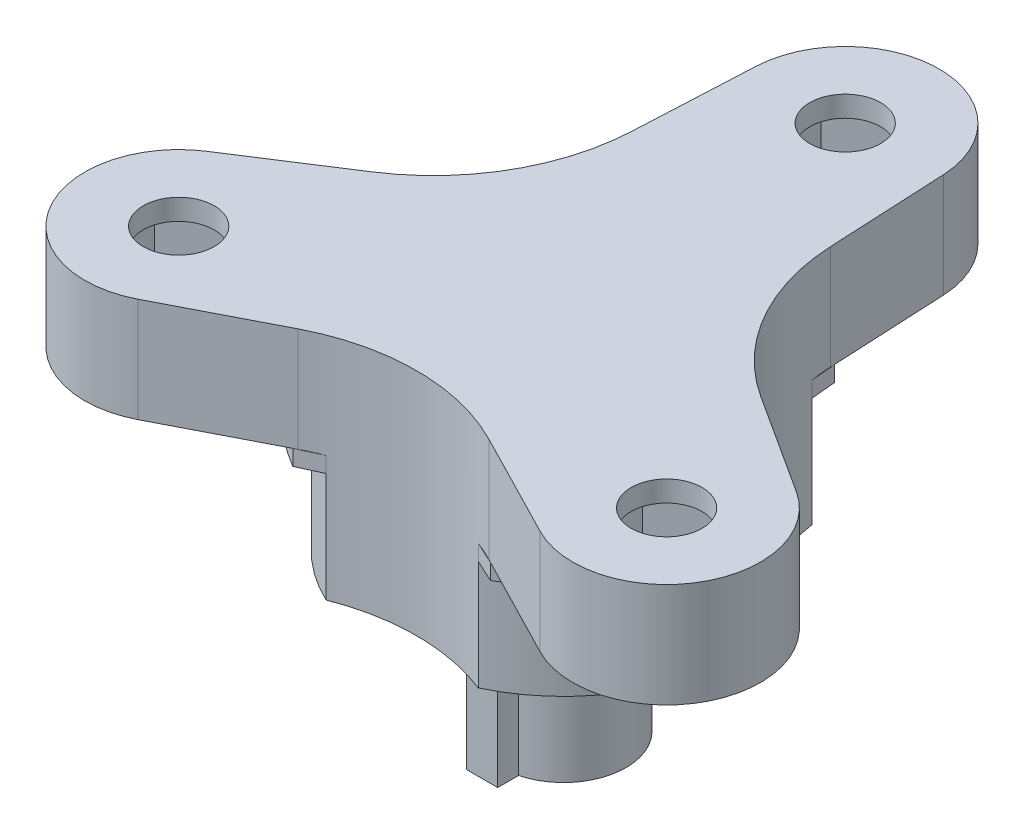
from build123d import *

# Parameters (mm, degrees)
SKETCH1_R           = 1.7
BOSS_EXTRUDE1_DEPTH = 5
CUT_EXTRUDE1_START  = -5
CUT_EXTRUDE1_DEPTH  = 4
BOSS_EXTRUDE2_DEPTH = 6
BOSS_EXTRUDE3_DEPTH = 0.75
BOSS_EXTRUDE4_DEPTH = 7.5
SKETCH7_R           = 1.3
CUT_EXTRUDE2_DEPTH  = 7.5


with BuildPart() as part:
    # Sketch1 → Boss-Extrude1 (new body)
    with BuildSketch(Plane(origin=(0, 0, 0), x_dir=(1, 0, 0), z_dir=(0, 1, 0))):
        with BuildLine():
            Line((-4.494644994, 13.719468408), (-4.772250922, 8.034184997))
            ThreePointArc((-4.772250922, 8.034184997), (-6.10009687, 3.52189257), (-9.343933767, 0.115798034))
            Line((-9.343933767, 0.115798034), (-14.128730664, -2.967257459))
            ThreePointArc((-14.128730664, -2.967257459), (-15.588457268, -9), (-9.634085671, -10.752210949))
            Line((-9.634085671, -10.752210949), (-4.571682845, -8.149983031))
            ThreePointArc((-4.571682845, -8.149983031), (0, -7.04378514), (4.571682845, -8.149983031))
            Line((4.571682845, -8.149983031), (9.634085671, -10.752210949))
            ThreePointArc((9.634085671, -10.752210949), (15.588457268, -9), (14.128730664, -2.967257459))
            Line((14.128730664, -2.967257459), (9.343933767, 0.115798034))
            ThreePointArc((9.343933767, 0.115798034), (6.10009687, 3.52189257), (4.772250922, 8.034184997))
            Line((4.772250922, 8.034184997), (4.494644994, 13.719468408))
            ThreePointArc((4.494644994, 13.719468408), (0, 18), (-4.494644994, 13.719468408))
        make_face()
        with Locations((0, 13.5)):
            Circle(SKETCH1_R, mode=Mode.SUBTRACT)
        with Locations((11.691342951, -6.75)):
            Circle(SKETCH1_R, mode=Mode.SUBTRACT)
        with Locations((-11.691342951, -6.75)):
            Circle(SKETCH1_R, mode=Mode.SUBTRACT)
    extrude(amount=BOSS_EXTRUDE1_DEPTH)

    # Sketch2 → Cut-Extrude1 (cut)
    with BuildSketch(Plane(origin=(0, 5, 0), x_dir=(1, 0, 0), z_dir=(0, 1, 0)).offset(CUT_EXTRUDE1_START)):
        Polygon((14.441342951, -8.33771324), (14.441342951, -5.16228676), (11.691342951, -3.574573519), (8.941342951, -5.16228676), (8.941342951, -8.33771324), (11.691342951, -9.925426481), align=None)
        Polygon((0, 16.675426481), (-2.75, 15.08771324), (-2.75, 11.91228676), (0, 10.324573519), (2.75, 11.91228676), (2.75, 15.08771324), align=None)
        Polygon((-14.441342951, -8.33771324), (-11.691342951, -9.925426481), (-8.941342951, -8.33771324), (-8.941342951, -5.16228676), (-11.691342951, -3.574573519), (-14.441342951, -5.16228676), align=None)
    extrude(amount=CUT_EXTRUDE1_DEPTH, mode=Mode.SUBTRACT)

    # Sketch4 → Boss-Extrude2 (add)
    with BuildSketch(Plane.XZ):
        with BuildLine():
            ThreePointArc((-4.872953171, -7.025441438), (0, -8.55), (4.872953171, -7.025441438))
            ThreePointArc((4.872953171, -7.025441438), (6.10009687, -3.52189257), (8.520687343, -0.707380519))
            ThreePointArc((8.520687343, -0.707380519), (7.404517202, 4.275), (3.647734172, 7.732821956))
            ThreePointArc((3.647734172, 7.732821956), (0, 7.04378514), (-3.647734172, 7.732821956))
            ThreePointArc((-3.647734172, 7.732821956), (-7.404517202, 4.275), (-8.520687343, -0.707380519))
            ThreePointArc((-8.520687343, -0.707380519), (-6.10009687, -3.52189257), (-4.872953171, -7.025441438))
        make_face()
    extrude(amount=BOSS_EXTRUDE2_DEPTH)

    # Sketch5 → Boss-Extrude3 (add)
    with BuildSketch(Plane.XZ):
        with BuildLine():
            Line((-9.499987767, -0.015245565), (-8.520687343, -0.707380519))
            ThreePointArc((-8.520687343, -0.707380519), (-7.404517202, 4.275), (-3.647734172, 7.732821956))
            Line((-3.647734172, 7.732821956), (-4.736790837, 8.234853524))
            ThreePointArc((-4.736790837, 8.234853524), (-8.227241336, 4.75), (-9.499987767, -0.015245565))
        make_face()
        with BuildLine():
            Line((9.499987767, -0.015245565), (8.520687343, -0.707380519))
            ThreePointArc((8.520687343, -0.707380519), (7.404517202, 4.275), (3.647734172, 7.732821956))
            Line((3.647734172, 7.732821956), (4.736790837, 8.234853524))
            ThreePointArc((4.736790837, 8.234853524), (8.227241336, 4.75), (9.499987767, -0.015245565))
        make_face()
        with BuildLine():
            Line((-4.76319693, -8.219607959), (-4.872953171, -7.025441438))
            ThreePointArc((-4.872953171, -7.025441438), (0, -8.55), (4.872953171, -7.025441438))
            Line((4.872953171, -7.025441438), (4.76319693, -8.219607959))
            ThreePointArc((4.76319693, -8.219607959), (0, -9.5), (-4.76319693, -8.219607959))
        make_face()
    extrude(amount=BOSS_EXTRUDE3_DEPTH)

    # Sketch6 → Boss-Extrude4 (add)
    with BuildSketch(Plane.XZ.offset(6)):
        with BuildLine():
            Line((-0.75, 2.90473751), (-0.75, 3.90473751))
            Line((-0.75, 3.90473751), (0.75, 3.90473751))
            Line((0.75, 3.90473751), (0.75, 2.90473751))
            ThreePointArc((0.75, 2.90473751), (0, -3), (-0.75, 2.90473751))
        make_face()
    extrude(amount=BOSS_EXTRUDE4_DEPTH)

    # Sketch7 → Cut-Extrude2 (cut)
    with BuildSketch(Plane.XZ.offset(13.5)):
        Circle(SKETCH7_R)
    extrude(amount=-CUT_EXTRUDE2_DEPTH, mode=Mode.SUBTRACT)


solid = part.part
